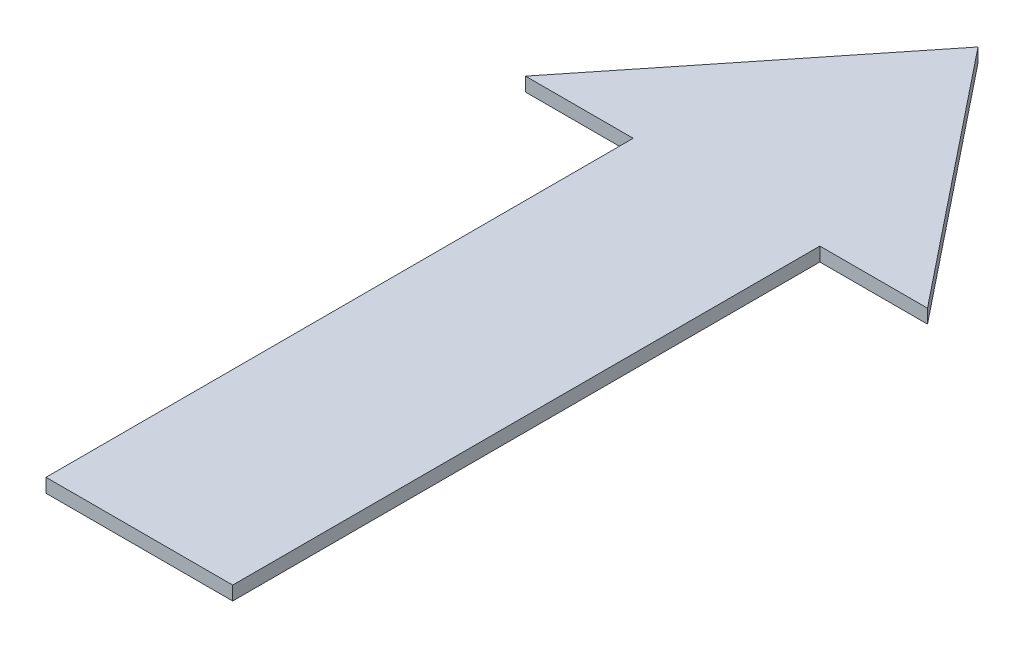
from build123d import *

# Parameters (mm, degrees)
BOSS_EXTRUDE1_DEPTH = 1


with BuildPart() as part:
    # Sketch1 → Boss-Extrude1 (new body)
    with BuildSketch(Plane(origin=(0, 0, 0), x_dir=(1, 0, 0), z_dir=(0, 1, 0))):
        Polygon((0, 0), (0, 42.446359223), (-7.781056627, 42.446359223), (6.747556904, 60.625748935), (21.276170435, 42.446359223), (13.495113808, 42.446359223), (13.495113808, 0), align=None)
    extrude(amount=BOSS_EXTRUDE1_DEPTH)


solid = part.part
